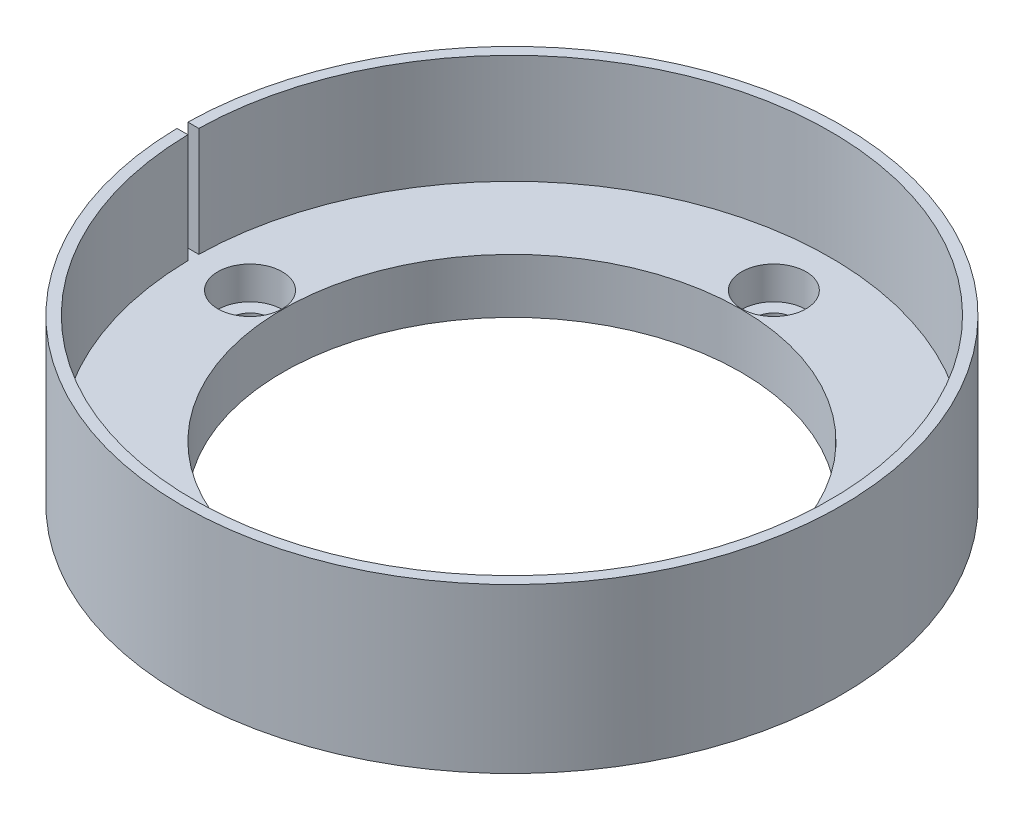
from build123d import *

# Parameters (mm, degrees)
CROQUIS2_R            = 1.7
CORTAR_EXTRUIR1_DEPTH = 10
CROQUIS3_R            = 2.95
CORTAR_EXTRUIR2_DEPTH = 3
CROQUIS4_W            = 10
CROQUIS4_H            = 1
CORTAR_EXTRUIR3_DEPTH = 10


with BuildPart() as part:
    # Croquis1 → Revolución1 (revolve)
    with BuildSketch(Plane.XY):
        Polygon((21, 0), (21, 5), (29.2, 5), (29.2, 15), (30.2, 15), (30.2, 0), align=None)
    revolve(axis=Axis((0, 26.816952267, 0), (0, -1, 0)))

    # Croquis2 → Cortar-Extruir1 (cut)
    with BuildSketch(Plane(origin=(0, 5, 0), x_dir=(1, 0, 0), z_dir=(0, 1, 0))):
        with Locations((-24, 0)):
            Circle(CROQUIS2_R)
        with Locations((0, 24)):
            Circle(CROQUIS2_R)
        with Locations((24, 0)):
            Circle(CROQUIS2_R)
        with Locations((0, -24)):
            Circle(CROQUIS2_R)
    extrude(amount=-CORTAR_EXTRUIR1_DEPTH, mode=Mode.SUBTRACT)

    # Croquis3 → Cortar-Extruir2 (cut)
    with BuildSketch(Plane(origin=(0, 5, 0), x_dir=(1, 0, 0), z_dir=(0, 1, 0))):
        with Locations((-24, 0)):
            Circle(CROQUIS3_R)
        with Locations((0, 24)):
            Circle(CROQUIS3_R)
        with Locations((24, 0)):
            Circle(CROQUIS3_R)
        with Locations((0, -24)):
            Circle(CROQUIS3_R)
    extrude(amount=-CORTAR_EXTRUIR2_DEPTH, mode=Mode.SUBTRACT)

    # Croquis4 → Cortar-Extruir3 (cut)
    with BuildSketch(Plane(origin=(0, 15, 0), x_dir=(1, 0, 0), z_dir=(0, 1, 0))):
        with Locations((-29.2, 0)):
            Rectangle(CROQUIS4_W, CROQUIS4_H)
    extrude(amount=-CORTAR_EXTRUIR3_DEPTH, mode=Mode.SUBTRACT)


solid = part.part
